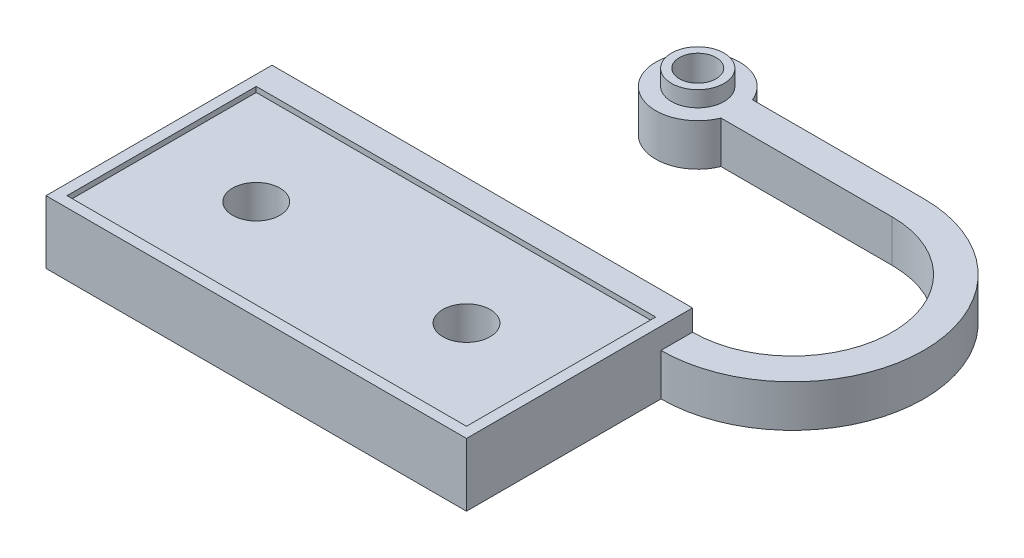
from build123d import *

# Parameters (mm, degrees)
SKETCH1_W           = 40
SKETCH1_H           = 21.5
SKETCH1_R           = 2.25
BOSS_EXTRUDE3_DEPTH = 6
SKETCH1_5_R         = 1.75
BOSS_EXTRUDE4_DEPTH = 4
SKETCH2_R           = 2.5
SKETCH2_R_2         = 1.75
BOSS_EXTRUDE5_DEPTH = 1.5
SKETCH3_W           = 38
SKETCH3_H           = 18
CUT_EXTRUDE1_DEPTH  = 0.5


with BuildPart() as part:
    # Sketch1 → Boss-Extrude3 (new body)
    with BuildSketch(Plane(origin=(0, 0, 0), x_dir=(1, 0, 0), z_dir=(0, 1, 0))):
        with Locations((0, 0.75)):
            Rectangle(SKETCH1_W, SKETCH1_H)
        with Locations((10, 0)):
            Circle(SKETCH1_R, mode=Mode.SUBTRACT)
        with Locations((-10, 0)):
            Circle(SKETCH1_R, mode=Mode.SUBTRACT)
    extrude(amount=BOSS_EXTRUDE3_DEPTH)

    # Sketch1_5 → Boss-Extrude4 (add)
    with BuildSketch(Plane(origin=(0, 0, 0), x_dir=(1, 0, 0), z_dir=(0, 1, 0))):
        with BuildLine():
            Line((20, 11.5), (20, 10))
            Line((20, 10), (20, 8.5))
            ThreePointArc((20, 8.5), (32.5, 21), (20, 33.5))
            Line((20, 33.5), (3.708099244, 33.5))
            ThreePointArc((3.708099244, 33.5), (-4, 32), (3.708099244, 30.5))
            Line((3.708099244, 30.5), (20, 30.5))
            ThreePointArc((20, 30.5), (29.5, 21), (20, 11.5))
        make_face()
        with Locations((0, 32)):
            Circle(SKETCH1_5_R, mode=Mode.SUBTRACT)
    extrude(amount=BOSS_EXTRUDE4_DEPTH)

    # Sketch2 → Boss-Extrude5 (add)
    with BuildSketch(Plane(origin=(0, 4, 0), x_dir=(1, 0, 0), z_dir=(0, 1, 0))):
        with Locations((0, 32)):
            Circle(SKETCH2_R)
        with Locations((0, 32)):
            Circle(SKETCH2_R_2, mode=Mode.SUBTRACT)
    extrude(amount=BOSS_EXTRUDE5_DEPTH)

    # Sketch3 → Cut-Extrude1 (cut)
    with BuildSketch(Plane(origin=(0, 6, 0), x_dir=(1, 0, 0), z_dir=(0, 1, 0))):
        Rectangle(SKETCH3_W, SKETCH3_H)
    extrude(amount=-CUT_EXTRUDE1_DEPTH, mode=Mode.SUBTRACT)


solid = part.part
